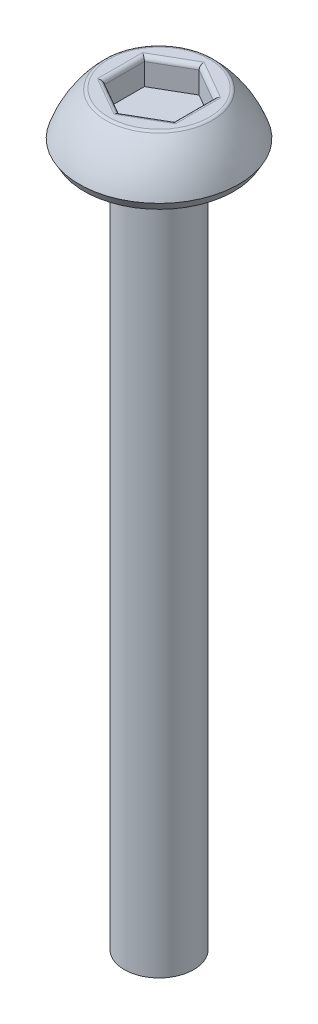
from build123d import *

# Parameters (mm, degrees)
CUT_EXTRUDE1_DEPTH = 0.75
FILLET1_R          = 0.125


with BuildPart() as part:
    # Sketch1 → Revolve1 (revolve)
    with BuildSketch(Plane(origin=(0, 0, 0), x_dir=(0, 0, -1), z_dir=(1, 0, 0))):
        with BuildLine():
            Line((0, 1.5), (-1.5, 1.5))
            ThreePointArc((-1.5, 1.5), (-1.978515811, 0.925250119), (-2.3, 0.25))
            Line((-2.3, 0.25), (-2.155662433, 0))
            Line((-2.155662433, 0), (-1, 0))
            Line((-1, 0), (-1, -20))
            Line((-1, -20), (0, -20))
            Line((0, -20), (0, 1.5))
        make_face()
    revolve(axis=Axis((0, -20, 0), (0, 1, 0)))

    # Sketch2 → Cut-Extrude1 (cut)
    with BuildSketch(Plane(origin=(0, 1.5, 0), x_dir=(1, 0, 0), z_dir=(0, 1, 0))):
        Polygon((0, 1.154700538), (-1, 0.577350269), (-1, -0.577350269), (0, -1.154700538), (1, -0.577350269), (1, 0.577350269), align=None)
    extrude(amount=-CUT_EXTRUDE1_DEPTH, mode=Mode.SUBTRACT)

    # Fillet1
    fillet1_edges = [part.edges().sort_by_distance(p)[0] for p in [
        (0.5, 1.5, -0.866025404),
        (-0.5, 1.5, -0.866025404),
        (-1, 1.5, 0),
        (-0.5, 1.5, 0.866025404),
        (0.5, 1.5, 0.866025404),
        (1, 1.5, 0),
        (0, 1.5, -1.5),
    ]]
    fillet(fillet1_edges, radius=FILLET1_R)


solid = part.part
